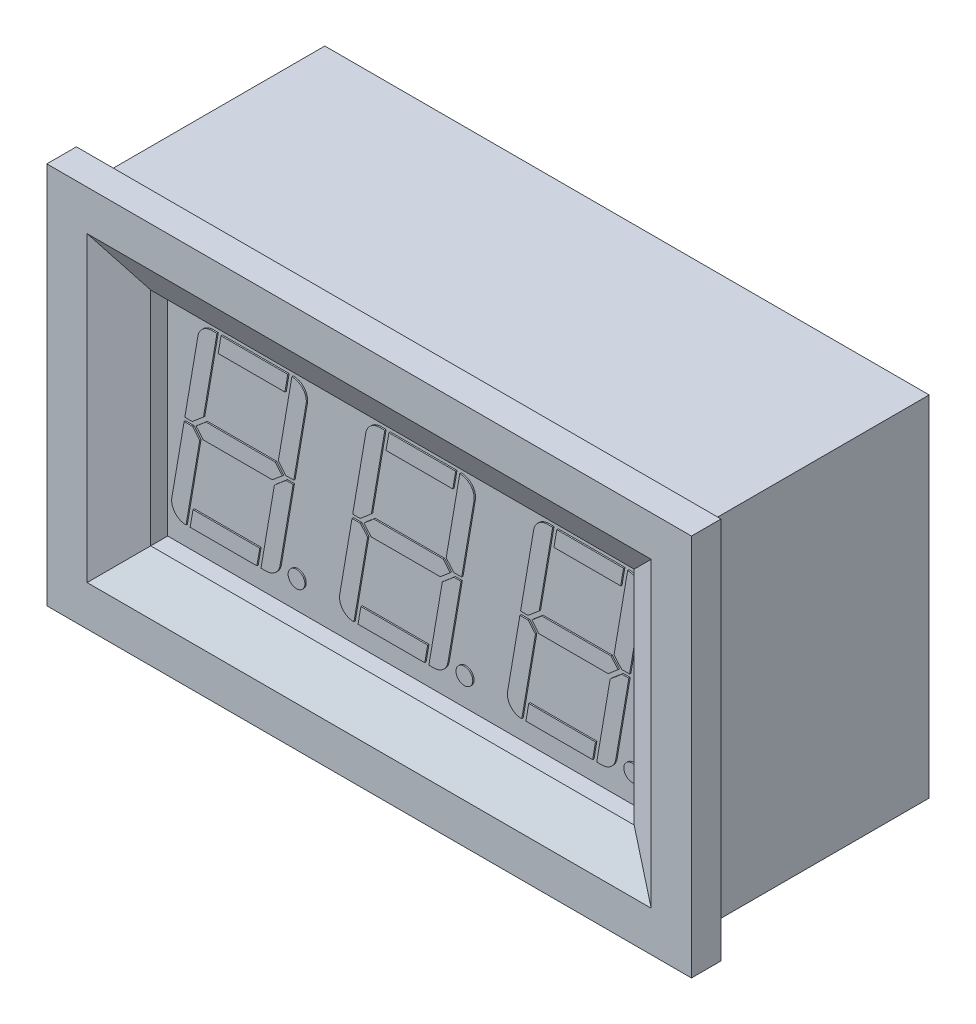
from build123d import *

# Parameters (mm, degrees)
SKETCH_1_W                    = 45
SKETCH_1_H                    = 26
BOSS_EXTRUDE1_DEPTH           = 17
SKETCH_W                      = 48
SKETCH_H                      = 28.5
BOSS_EXTRUDE2_DEPTH           = 2.2
SKETCH_3_W                    = 36
SKETCH_3_H                    = 16.5
CUT_EXTRUDE1_DEPTH            = 3
CHAMFER_1_SIZE                = 3
CHAMFER_1_SIZE2               = 1.732050808
SKETCH_4_R                    = 0.625
BOSS_EXTRUDE3_DEPTH           = 0.1
ROUNDING_1_R                  = 1.05
LINEAR_ARRAY1_COUNT           = 3
LINEAR_ARRAY1_PITCH           = 12.5
ROUNDING_1_OF_LINEAR_ARRAY1_R = 1.05


with BuildPart() as part:
    # sketch 1 → Boss-Extrude1 (new body)
    with BuildSketch(Plane.XY):
        Rectangle(SKETCH_1_W, SKETCH_1_H)
    extrude(amount=BOSS_EXTRUDE1_DEPTH)

    # sketch → Boss-Extrude2 (add)
    with BuildSketch(Plane.XY.offset(17)):
        Rectangle(SKETCH_W, SKETCH_H)
    extrude(amount=BOSS_EXTRUDE2_DEPTH)

    # sketch 3 → Cut-Extrude1 (cut)
    with BuildSketch(Plane.XY.offset(19.2)):
        Rectangle(SKETCH_3_W, SKETCH_3_H)
    extrude(amount=-CUT_EXTRUDE1_DEPTH, mode=Mode.SUBTRACT)

    # chamfer 1
    chamfer_1_edges = [part.edges().sort_by_distance(p)[0] for p in [
        (-18, 0, 19.2),
        (0, -8.25, 19.2),
        (18, 0, 19.2),
        (0, 8.25, 19.2),
    ]]
    chamfer_1_side = [part.faces().sort_by_distance(p)[0] for p in [
        (0, -13.691766178, 19.2),
    ]]
    chamfer(chamfer_1_edges, length=CHAMFER_1_SIZE, length2=CHAMFER_1_SIZE2, reference=chamfer_1_side[0])

    # sketch 4 → Boss-Extrude3 (add)
    with BuildSketch(Plane.XY.offset(16.2)):
        with Locations((-8.310233245, -6.125)):
            Circle(SKETCH_4_R)
        Polygon((-17.8, -6.75), (-16.531988477, -6.75), (-15.515440373, -0.783304607), (-16.049974064, -0.15), (-16.675555556, -0.15), align=None)
        Polygon((-9.68472625, -6.75), (-8.560281805, -0.15), (-9.077616658, -0.15), (-9.954369729, -0.890013653), (-10.952737773, -6.75), align=None)
        Polygon((-15.5, 6.75), (-14.231988477, 6.75), (-15.236353449, 0.854814294), (-16.071403038, 0.15), (-16.624444444, 0.15), align=None)
        Polygon((-8.509170694, 0.15), (-9.099045632, 0.15), (-9.66328895, 0.818503966), (-8.652737773, 6.75), (-7.38472625, 6.75), align=None)
        Polygon((-15.784003603, 0), (-15.04351636, 0.625), (-9.892540373, 0.625), (-9.365016093, 0), (-10.105503336, -0.625), (-15.256479323, -0.625), align=None)
        Polygon((-13.927665711, 6.75), (-14.140628674, 5.5), (-9.170023502, 5.5), (-8.957060539, 6.75), align=None)
        Polygon((-16.227665711, -6.75), (-16.014702748, -5.5), (-11.044097576, -5.5), (-11.257060539, -6.75), align=None)
    boss_extrude3 = extrude(amount=BOSS_EXTRUDE3_DEPTH)

    # rounding 1
    rounding_1_edges = [part.edges().sort_by_distance(p)[0] for p in [
        (-17.8, -6.75, 16.25),
        (-9.68472625, -6.75, 16.25),
        (-7.38472625, 6.75, 16.25),
        (-15.5, 6.75, 16.25),
    ]]
    fillet(rounding_1_edges, radius=ROUNDING_1_R)

    # Linear array1: Boss-Extrude3 ×3
    with Locations(*[(i * LINEAR_ARRAY1_PITCH, 0, 0) for i in range(1, LINEAR_ARRAY1_COUNT)]):
        add(boss_extrude3)

    # rounding 1 of Linear array1
    rounding_1_of_linear_array1_edges = [part.edges().sort_by_distance(p)[0] for p in [
        (-5.3, -6.75, 16.25),
        (2.81527375, -6.75, 16.25),
        (5.11527375, 6.75, 16.25),
        (-3, 6.75, 16.25),
        (7.2, -6.75, 16.25),
        (15.31527375, -6.75, 16.25),
        (17.61527375, 6.75, 16.25),
        (9.5, 6.75, 16.25),
    ]]
    fillet(rounding_1_of_linear_array1_edges, radius=ROUNDING_1_OF_LINEAR_ARRAY1_R)


solid = part.part
